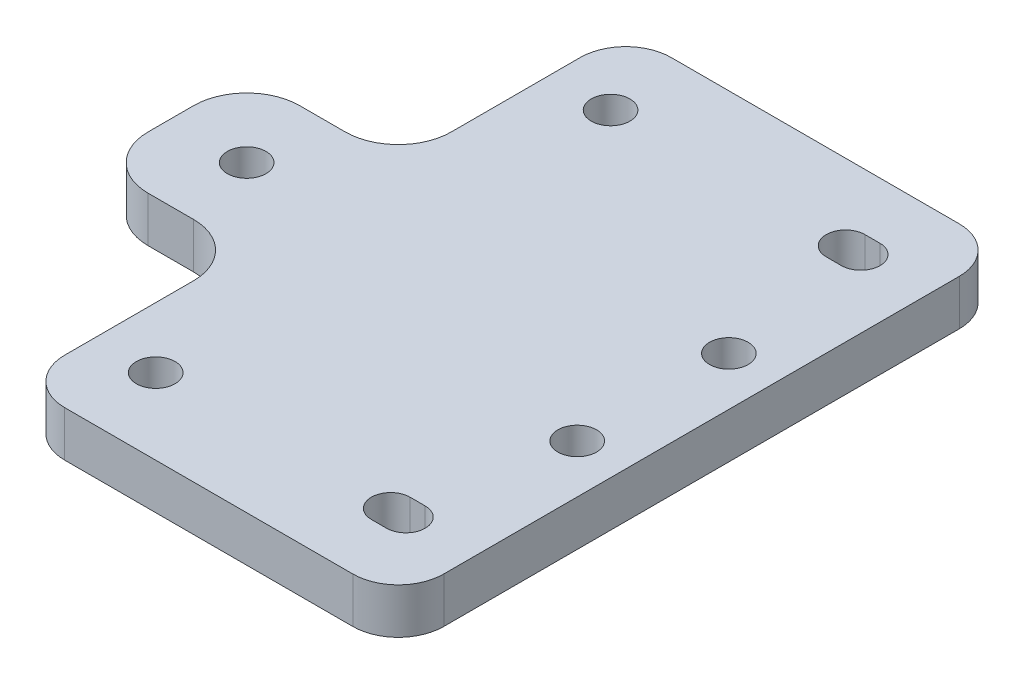
from build123d import *

# Parameters (mm, degrees)
SKETCH_1_R          = 2.55
EXTRUDE_1_DEPTH     = 6
SKETCH_2_R          = 2.55
CUT_EXTRUDE_1_DEPTH = 7


with BuildPart() as part:
    # Эскиз1 → Бобышка-Вытянуть1 (new body)
    with BuildSketch(Plane(origin=(0, 0, 0), x_dir=(1, 0, 0), z_dir=(0, 1, 0))):
        with BuildLine():
            Line((-32, -10), (-38, -10))
            ThreePointArc((-38, -10), (-42.949747468, -7.949747468), (-45, -3))
            Line((-45, -3), (-45, 3))
            ThreePointArc((-45, 3), (-42.949747468, 7.949747468), (-38, 10))
            Line((-38, 10), (-32, 10))
            ThreePointArc((-32, 10), (-27.050252532, 12.050252532), (-25, 17))
            Line((-25, 17), (-25, 34))
            ThreePointArc((-25, 34), (-23.242640687, 38.242640687), (-19, 40))
            Line((-19, 40), (19, 40))
            ThreePointArc((19, 40), (23.242640687, 38.242640687), (25, 34))
            Line((25, 34), (25, -34))
            ThreePointArc((25, -34), (23.242640687, -38.242640687), (19, -40))
            Line((19, -40), (-19, -40))
            ThreePointArc((-19, -40), (-23.242640687, -38.242640687), (-25, -34))
            Line((-25, -34), (-25, -17))
            ThreePointArc((-25, -17), (-27.050252532, -12.050252532), (-32, -10))
        make_face()
        with Locations((-35, 0)):
            Circle(SKETCH_1_R, mode=Mode.SUBTRACT)
        with Locations((18.605, 10)):
            Circle(SKETCH_1_R, mode=Mode.SUBTRACT)
        with Locations((18.605, -10)):
            Circle(SKETCH_1_R, mode=Mode.SUBTRACT)
    extrude(amount=EXTRUDE_1_DEPTH)

    # Эскиз2 → Вырез-Вытянуть1 (cut, through all)
    with BuildSketch(Plane.XZ):
        with Locations((-17, -30)):
            Circle(SKETCH_2_R)
        with Locations((-17, 30)):
            Circle(SKETCH_2_R)
        with BuildLine():
            Line((16, -32.55), (14, -32.55))
            ThreePointArc((14, -32.55), (11.45, -30), (14, -27.45))
            Line((14, -27.45), (16, -27.45))
            ThreePointArc((16, -27.45), (18.55, -30), (16, -32.55))
        make_face()
        with BuildLine():
            Line((16, 32.55), (14, 32.55))
            ThreePointArc((14, 32.55), (11.45, 30), (14, 27.45))
            Line((14, 27.45), (16, 27.45))
            ThreePointArc((16, 27.45), (18.55, 30), (16, 32.55))
        make_face()
    extrude(amount=-CUT_EXTRUDE_1_DEPTH, mode=Mode.SUBTRACT)


solid = part.part
